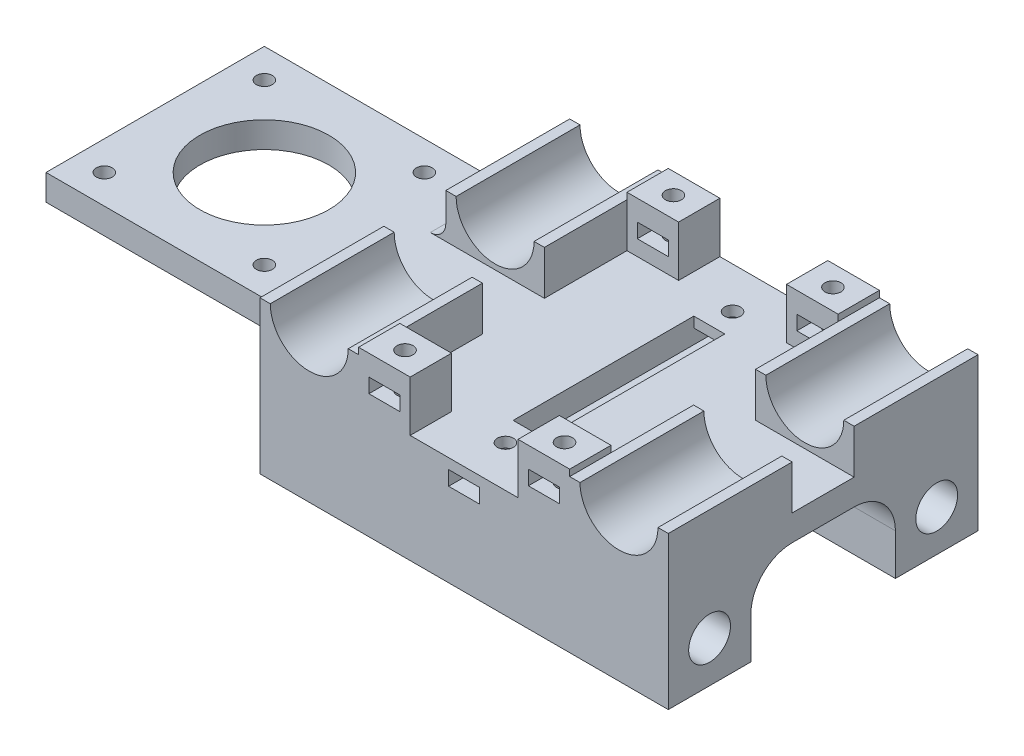
from build123d import *

# Parameters (mm, degrees)
SKETCH1_W                 = 79.1
SKETCH1_H                 = 60
BOSS_EXTRUDE1_DEPTH       = 5
BOSS_EXTRUDE2_DEPTH       = 24
MIRROR2_COPY_1_DEPTH      = 24
SKETCH9_W                 = 10
SKETCH9_H                 = 9.8
SKETCH9_W_2               = 6
SKETCH9_H_2               = 2.8
BOSS_EXTRUDE4_DEPTH       = 8
MIRROR9_COPY_1_SKETCH_W   = 10
MIRROR9_COPY_1_SKETCH_H   = 9.8
MIRROR9_COPY_1_SKETCH_W_2 = 6
MIRROR9_COPY_1_SKETCH_H_2 = 2.8
MIRROR9_COPY_1_DEPTH      = 8
SKETCH10_R                = 1.55
CUT_EXTRUDE6_DEPTH        = 15.8
SKETCH11_W                = 79.1
SKETCH11_H                = 16
BOSS_EXTRUDE5_DEPTH       = 16
SKETCH12_R                = 4.05
CUT_EXTRUDE7_DEPTH        = 80.1
SKETCH13_W                = 6
SKETCH13_H                = 2.8
CUT_EXTRUDE8_DEPTH        = 61
SKETCH14_R                = 1.55
CUT_EXTRUDE9_DEPTH        = 10
SKETCH14_3_W              = 6
SKETCH14_3_H              = 35
CUT_EXTRUDE10_DEPTH       = 4.8
FILLET1_R                 = 8
SKETCH15_W                = 50.3
SKETCH15_H                = 42.3
SKETCH15_R                = 1.55
SKETCH15_R_2              = 12.5
BOSS_EXTRUDE6_DEPTH       = 5
FILLET3_R                 = 3


with BuildPart() as part:
    # Sketch1 → Boss-Extrude1 (new body)
    with BuildSketch(Plane(origin=(0, 0, 0), x_dir=(1, 0, 0), z_dir=(0, 1, 0))):
        Rectangle(SKETCH1_W, SKETCH1_H)
    extrude(amount=BOSS_EXTRUDE1_DEPTH)

    # Sketch2 → Boss-Extrude2 (add)
    with BuildSketch(Plane.XY.offset(30)):
        with BuildLine():
            Line((-39.55, 13.55), (-39.55, 5))
            Line((-39.55, 5), (-20.45, 5))
            Line((-20.45, 5), (-20.45, 13.55))
            Line((-20.45, 13.55), (-22.45, 13.55))
            ThreePointArc((-22.45, 13.55), (-30, 6), (-37.55, 13.55))
            Line((-37.55, 13.55), (-39.55, 13.55))
        make_face()
    boss_extrude2 = extrude(amount=-BOSS_EXTRUDE2_DEPTH)

    # Mirror1: Boss-Extrude2 across plane
    add(boss_extrude2.mirror(Plane.XY))

    # Mirror2: Boss-Extrude2 across plane
    add(boss_extrude2.mirror(Plane(origin=(0, 0, 0), x_dir=(0, 0, 1), z_dir=(1, 0, 0))))

    # Mirror2 copy 1 sketch → Mirror2 copy 1 (add)
    with BuildSketch(Plane(origin=(0, 0, -30), x_dir=(-1, 0, 0), z_dir=(0, 0, -1))):
        with BuildLine():
            Line((-39.55, 13.55), (-39.55, 5))
            Line((-39.55, 5), (-20.45, 5))
            Line((-20.45, 5), (-20.45, 13.55))
            Line((-20.45, 13.55), (-22.45, 13.55))
            ThreePointArc((-22.45, 13.55), (-30, 6), (-37.55, 13.55))
            Line((-37.55, 13.55), (-39.55, 13.55))
        make_face()
    extrude(amount=-MIRROR2_COPY_1_DEPTH)

    # Sketch9 → Boss-Extrude4 (add)
    with BuildSketch(Plane.XY.offset(30)):
        with Locations((-15.45, 9.9)):
            Rectangle(SKETCH9_W, SKETCH9_H)
        with Locations((-15.45, 9.4)):
            Rectangle(SKETCH9_W_2, SKETCH9_H_2, mode=Mode.SUBTRACT)
    boss_extrude4 = extrude(amount=-BOSS_EXTRUDE4_DEPTH)

    # Mirror8: Boss-Extrude4 across plane
    add(boss_extrude4.mirror(Plane(origin=(0, 0, 0), x_dir=(0, 0, 1), z_dir=(1, 0, 0))))

    # Mirror9: Boss-Extrude4 across plane
    add(boss_extrude4.mirror(Plane.XY))

    # Mirror9 copy 1 sketch → Mirror9 copy 1 (add)
    with BuildSketch(Plane(origin=(0, 0, -30), x_dir=(-1, 0, 0), z_dir=(0, 0, -1))):
        with Locations((-15.45, 9.9)):
            Rectangle(MIRROR9_COPY_1_SKETCH_W, MIRROR9_COPY_1_SKETCH_H)
        with Locations((-15.45, 9.4)):
            Rectangle(MIRROR9_COPY_1_SKETCH_W_2, MIRROR9_COPY_1_SKETCH_H_2, mode=Mode.SUBTRACT)
    extrude(amount=-MIRROR9_COPY_1_DEPTH)

    # Sketch10 → Cut-Extrude6 (cut, through all)
    with BuildSketch(Plane(origin=(0, 14.8, 0), x_dir=(1, 0, 0), z_dir=(0, 1, 0))):
        with Locations(Location((-15.45, 26, 0), (0, 0, 270))):  # turned: the seam where the file's is
            Circle(SKETCH10_R)
        with Locations(Location((15.45, 26, 0), (0, 0, 270))):  # turned: the seam where the file's is
            Circle(SKETCH10_R)
        with Locations(Location((15.45, -26, 0), (0, 0, 270))):  # turned: the seam where the file's is
            Circle(SKETCH10_R)
        with Locations(Location((-15.45, -26, 0), (0, 0, 270))):  # turned: the seam where the file's is
            Circle(SKETCH10_R)
    extrude(amount=-CUT_EXTRUDE6_DEPTH, mode=Mode.SUBTRACT)

    # Sketch11 → Boss-Extrude5 (add)
    with BuildSketch(Plane.XZ):
        with Locations((0, 22)):
            Rectangle(SKETCH11_W, SKETCH11_H)
        with Locations((0, -22)):
            Rectangle(SKETCH11_W, SKETCH11_H)
    extrude(amount=BOSS_EXTRUDE5_DEPTH)

    # Sketch12 → Cut-Extrude7 (cut, through all)
    with BuildSketch(Plane(origin=(39.55, 0, 0), x_dir=(0, 0, -1), z_dir=(1, 0, 0))):
        with Locations((-22, -8)):
            Circle(SKETCH12_R)
        with Locations((22, -8)):
            Circle(SKETCH12_R)
    extrude(amount=-CUT_EXTRUDE7_DEPTH, mode=Mode.SUBTRACT)

    # Sketch13 → Cut-Extrude8 (cut, through all)
    with BuildSketch(Plane(origin=(0, 0, -30), x_dir=(-1, 0, 0), z_dir=(0, 0, -1))):
        with Locations((0, 1.6)):
            Rectangle(SKETCH13_W, SKETCH13_H)
    extrude(amount=-CUT_EXTRUDE8_DEPTH, mode=Mode.SUBTRACT)

    # Sketch14 → Cut-Extrude9 (cut)
    with BuildSketch(Plane(origin=(0, 5, 0), x_dir=(1, 0, 0), z_dir=(0, 1, 0))):
        with Locations(Location((0, -22, 0), (0, 0, 270))):  # turned: the seam where the file's is
            Circle(SKETCH14_R)
        with Locations(Location((0, 22, 0), (0, 0, 270))):  # turned: the seam where the file's is
            Circle(SKETCH14_R)
    extrude(amount=-CUT_EXTRUDE9_DEPTH, mode=Mode.SUBTRACT)

    # Sketch14_3 → Cut-Extrude10 (cut)
    with BuildSketch(Plane(origin=(0, 5, 0), x_dir=(1, 0, 0), z_dir=(0, 1, 0))):
        Rectangle(SKETCH14_3_W, SKETCH14_3_H)
    extrude(amount=-CUT_EXTRUDE10_DEPTH, mode=Mode.SUBTRACT)

    # Fillet1
    fillet1_edges = [part.edges().sort_by_distance(p)[0] for p in [
        (0, 0, -14),
        (0, 0, 14),
    ]]
    fillet(fillet1_edges, radius=FILLET1_R)

    # Sketch15 → Boss-Extrude6 (add)
    with BuildSketch(Plane.XZ):
        with Locations((-64.7, 0)):
            Rectangle(SKETCH15_W, SKETCH15_H)
        with Locations(Location((-84.2, 15.5, 0), (0, 0, 270))):  # turned: the seam where the file's is
            Circle(SKETCH15_R, mode=Mode.SUBTRACT)
        with Locations(Location((-84.2, -15.5, 0), (0, 0, 270))):  # turned: the seam where the file's is
            Circle(SKETCH15_R, mode=Mode.SUBTRACT)
        with Locations(Location((-53.2, -15.5, 0), (0, 0, 270))):  # turned: the seam where the file's is
            Circle(SKETCH15_R, mode=Mode.SUBTRACT)
        with Locations(Location((-53.2, 15.5, 0), (0, 0, 270))):  # turned: the seam where the file's is
            Circle(SKETCH15_R, mode=Mode.SUBTRACT)
        with Locations(Location((-68.7, 0, 0), (0, 0, 270))):  # turned: the seam where the file's is
            Circle(SKETCH15_R_2, mode=Mode.SUBTRACT)
    extrude(amount=-BOSS_EXTRUDE6_DEPTH)

    # Fillet3
    fillet3_edges = [part.edges().sort_by_distance(p)[0] for p in [
        (-39.55, 5, -13.575),
        (-39.55, 5, 13.575),
    ]]
    fillet(fillet3_edges, radius=FILLET3_R)


solid = part.part
